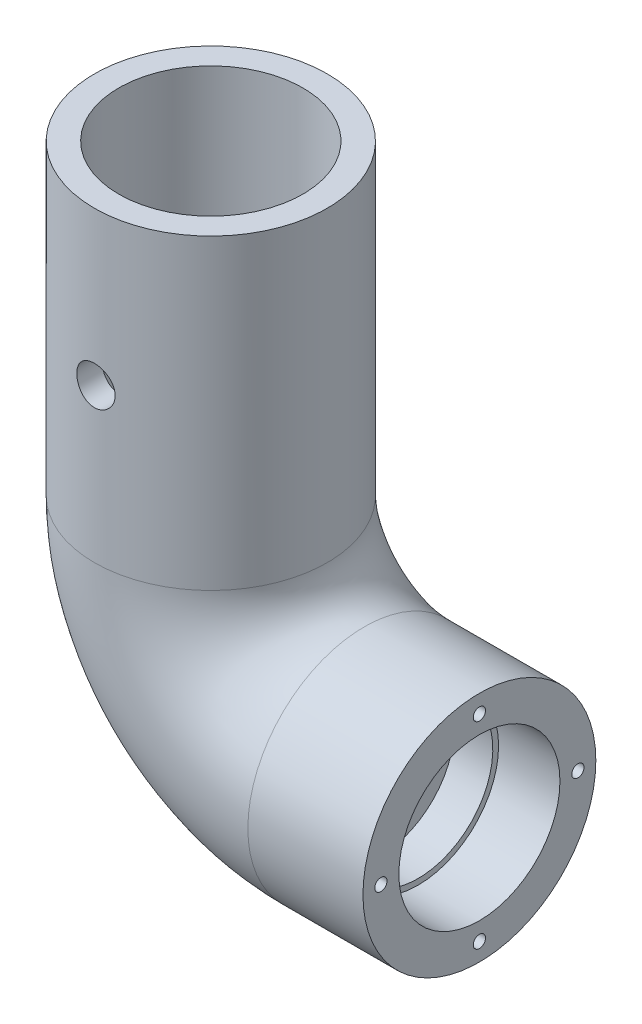
from build123d import *

# Parameters (mm, degrees)
SKETCH1_R                       = 15.175
SKETCH1_R_2                     = 12
SKETCH3_R                       = 12
BOSS_EXTRUDE1_DEPTH             = 2
SKETCH4_R                       = 12
SKETCH4_R_2                     = 9.75
BOSS_EXTRUDE4_DEPTH             = 5
SKETCH6_R                       = 12
SKETCH6_R_2                     = 10.5
BOSS_EXTRUDE5_DEPTH             = 8
SKETCH7_R                       = 2.5
CUT_EXTRUDE2_DEPTH              = 16.1750001
CUT_EXTRUDE2_DEPTH_BACK         = 16.1750001
TAP_DRILL_FOR_M2X0_4_TAP1_D     = 1.6
TAP_DRILL_FOR_M2X0_4_TAP1_DEPTH = 10
TAP_DRILL_FOR_M2X0_4_TAP1_TIP   = 0.480688495


with BuildPart() as part:
    # Sweep1: sweep along a path in Sketch2
    with BuildLine(Plane.XY) as sweep1_path:
        Line((0, 0), (0, -40))
        ThreePointArc((0, -40), (5.857864376, -54.142135624), (20, -60))
        Line((20, -60), (35, -60))
    # Sketch1 → Sweep1 (sweep)
    with BuildSketch(Plane(origin=(0, 0, 0), x_dir=(1, 0, 0), z_dir=(0, 1, 0))):
        Circle(SKETCH1_R)
        Circle(SKETCH1_R_2, mode=Mode.SUBTRACT)
    sweep(path=sweep1_path.line)

    # Sketch3 → Boss-Extrude1 (add)
    with BuildSketch(Plane(origin=(20, 0, 0), x_dir=(0, 0, -1), z_dir=(1, 0, 0))):
        with Locations((0, -60)):
            Circle(SKETCH3_R)
    extrude(amount=BOSS_EXTRUDE1_DEPTH)

    # Sketch4 → Boss-Extrude4 (add)
    with BuildSketch(Plane(origin=(22, 0, 0), x_dir=(0, 0, -1), z_dir=(1, 0, 0))):
        with Locations((0, -60)):
            Circle(SKETCH4_R)
        with Locations((0, -60)):
            Circle(SKETCH4_R_2, mode=Mode.SUBTRACT)
    extrude(amount=BOSS_EXTRUDE4_DEPTH)

    # Sketch6 → Boss-Extrude5 (add)
    with BuildSketch(Plane(origin=(27, 0, 0), x_dir=(0, 0, -1), z_dir=(1, 0, 0))):
        with Locations((0, -60)):
            Circle(SKETCH6_R)
        with Locations((0, -60)):
            Circle(SKETCH6_R_2, mode=Mode.SUBTRACT)
    extrude(amount=BOSS_EXTRUDE5_DEPTH)

    # Sketch7 → Cut-Extrude2 (cut, two sides)
    with BuildSketch(Plane.XY) as cut_extrude2_sk:
        with Locations((0, -20)):
            Circle(SKETCH7_R)
    extrude(amount=CUT_EXTRUDE2_DEPTH, mode=Mode.SUBTRACT)
    extrude(cut_extrude2_sk.sketch, amount=-CUT_EXTRUDE2_DEPTH_BACK, mode=Mode.SUBTRACT)

    # Tap Drill for M2x0.4 Tap1
    with Locations(Plane(origin=(35, 0, 0), x_dir=(0, 0, -1), z_dir=(1, 0, 0))):
        with Locations((0, -47.1625), (12.8375, -60), (0, -72.8375), (-12.8375, -60)):
            Hole(TAP_DRILL_FOR_M2X0_4_TAP1_D / 2, depth=TAP_DRILL_FOR_M2X0_4_TAP1_DEPTH)
            with Locations((0, 0, -(TAP_DRILL_FOR_M2X0_4_TAP1_DEPTH + TAP_DRILL_FOR_M2X0_4_TAP1_TIP / 2))):  # 118° drill point
                Cone(0, TAP_DRILL_FOR_M2X0_4_TAP1_D / 2, TAP_DRILL_FOR_M2X0_4_TAP1_TIP, mode=Mode.SUBTRACT)


solid = part.part
